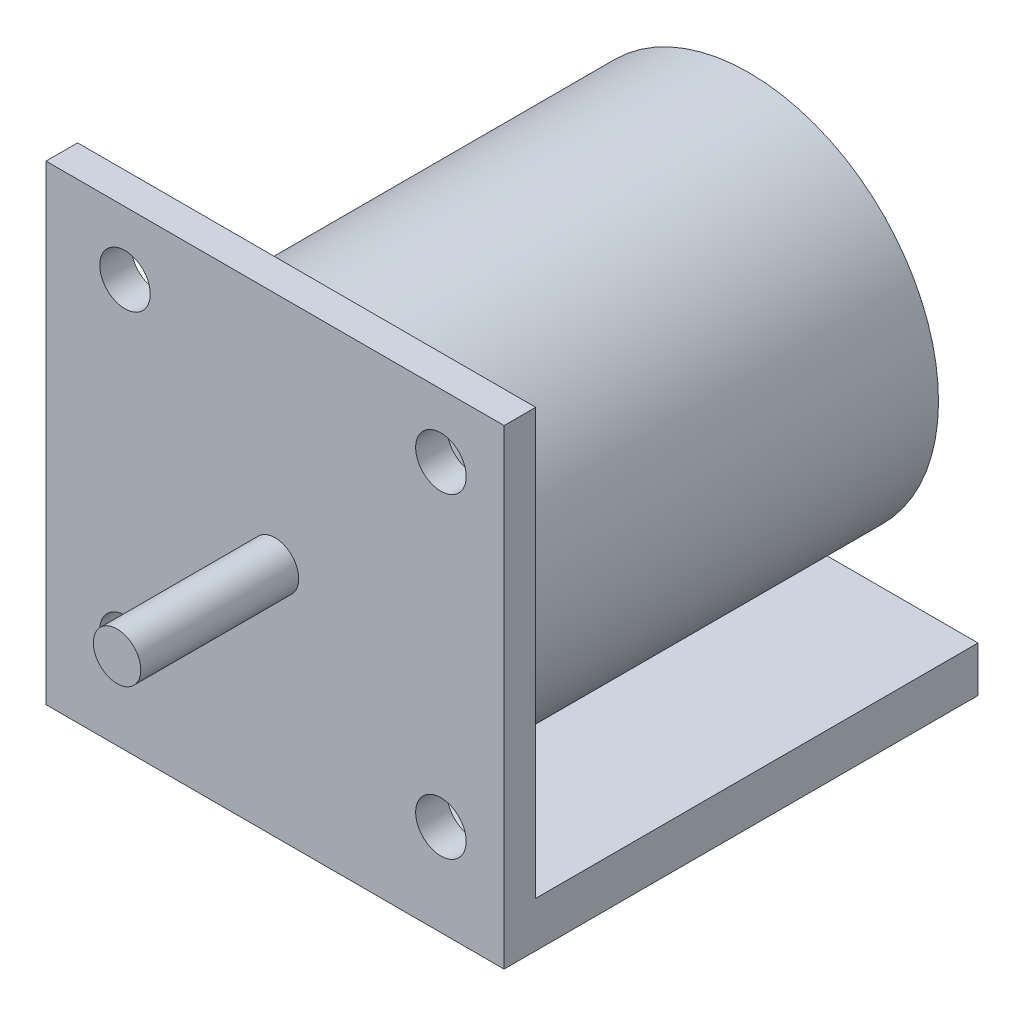
from build123d import *

# Parameters (mm, degrees)
SKETCH1_W           = 36.83
SKETCH1_H           = 37.846
BOSS_EXTRUDE1_DEPTH = 2.54
SKETCH2_R           = 1.905
BOSS_EXTRUDE2_DEPTH = 12.7
SKETCH3_R           = 15.24
BOSS_EXTRUDE3_DEPTH = 35.56
SKETCH4_W           = 36.83
SKETCH4_H           = 3.657403599
BOSS_EXTRUDE4_DEPTH = 35.56
SKETCH5_R           = 2.032
CUT_EXTRUDE1_DEPTH  = 35.56


with BuildPart() as part:
    # Sketch1 → Boss-Extrude1 (new body)
    with BuildSketch(Plane.XY):
        Rectangle(SKETCH1_W, SKETCH1_H)
    extrude(amount=BOSS_EXTRUDE1_DEPTH)

    # Sketch2 → Boss-Extrude2 (add)
    with BuildSketch(Plane.XY.offset(2.54)):
        with Locations(Location((0, 0, 0), (0, 0, 180))):  # turned: the seam where the file's is
            Circle(SKETCH2_R)
    extrude(amount=BOSS_EXTRUDE2_DEPTH)

    # Sketch3 → Boss-Extrude3 (add)
    with BuildSketch(Plane(origin=(0, 0, 0), x_dir=(-1, 0, 0), z_dir=(0, 0, -1))):
        Circle(SKETCH3_R)
    extrude(amount=BOSS_EXTRUDE3_DEPTH)

    # Sketch4 → Boss-Extrude4 (add)
    with BuildSketch(Plane(origin=(0, 0, 0), x_dir=(-1, 0, 0), z_dir=(0, 0, -1))):
        with Locations((0, -17.094298201)):
            Rectangle(SKETCH4_W, SKETCH4_H)
    extrude(amount=BOSS_EXTRUDE4_DEPTH)

    # Sketch5 → Cut-Extrude1 (cut)
    with BuildSketch(Plane.XY.offset(2.54)):
        with Locations((13.335, 13.843)):
            Circle(SKETCH5_R)
        with Locations((-12.065, 13.843)):
            Circle(SKETCH5_R)
        with Locations((-12.065, -11.557)):
            Circle(SKETCH5_R)
        with Locations((13.335, -11.557)):
            Circle(SKETCH5_R)
    extrude(amount=-CUT_EXTRUDE1_DEPTH, mode=Mode.SUBTRACT)


solid = part.part
